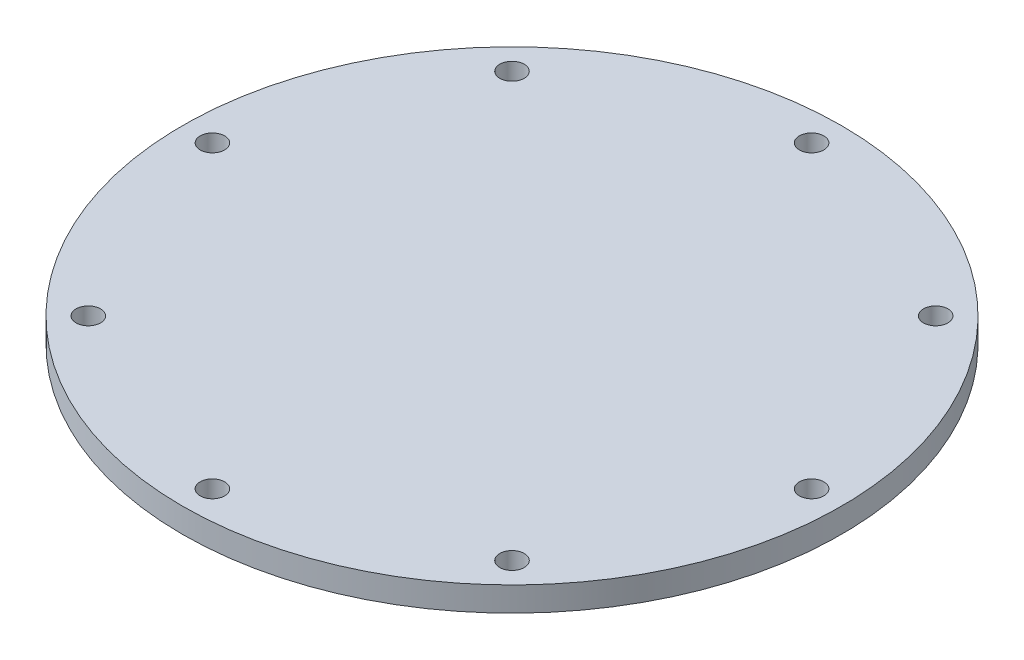
from build123d import *

# Parameters (mm, degrees)
SKETCH1_R           = 26.95
SKETCH1_R_2         = 1
BOSS_EXTRUDE1_DEPTH = 2


with BuildPart() as part:
    # Sketch1 → Boss-Extrude1 (new body)
    with BuildSketch(Plane(origin=(0, 0, 0), x_dir=(1, 0, 0), z_dir=(0, 1, 0))):
        Circle(SKETCH1_R)
        with Locations((0, 24.5)):
            Circle(SKETCH1_R_2, mode=Mode.SUBTRACT)
        with Locations((17.324116139, 17.324116139)):
            Circle(SKETCH1_R_2, mode=Mode.SUBTRACT)
        with Locations((24.5, 0)):
            Circle(SKETCH1_R_2, mode=Mode.SUBTRACT)
        with Locations((17.324116139, -17.324116139)):
            Circle(SKETCH1_R_2, mode=Mode.SUBTRACT)
        with Locations((0, -24.5)):
            Circle(SKETCH1_R_2, mode=Mode.SUBTRACT)
        with Locations((-17.324116139, -17.324116139)):
            Circle(SKETCH1_R_2, mode=Mode.SUBTRACT)
        with Locations((-24.5, 0)):
            Circle(SKETCH1_R_2, mode=Mode.SUBTRACT)
        with Locations((-17.324116139, 17.324116139)):
            Circle(SKETCH1_R_2, mode=Mode.SUBTRACT)
    extrude(amount=BOSS_EXTRUDE1_DEPTH)


solid = part.part
